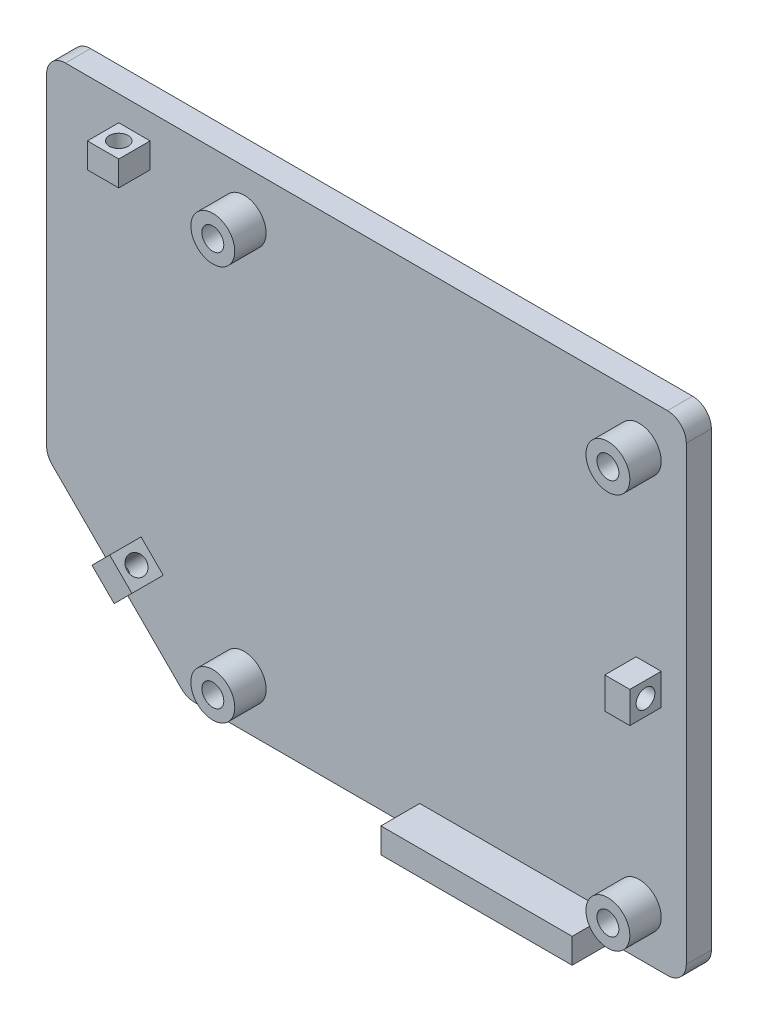
from build123d import *

# Parameters (mm, degrees)
CROQUIS1_W                 = 102
CROQUIS1_H                 = 78
SALIENTE_EXTRUIR1_DEPTH    = 4
CROQUIS2_R                 = 1.75
CORTAR_EXTRUIR1_DEPTH      = 4
CROQUIS3_R                 = 3.5
CROQUIS3_R_2               = 1.75
SALIENTE_EXTRUIR2_DEPTH    = 5
CROQUIS4_W                 = 30.5
CROQUIS4_H                 = 4
SALIENTE_EXTRUIR3_DEPTH    = 6.2
SALIENTE_EXTRUIR4_DEPTH    = 5
CROQUIS7_R                 = 1.5
CORTAR_EXTRUIR3_DEPTH      = 5
CORTAR_EXTRUIR5_DEPTH      = 7.2
CORTAR_EXTRUIR5_DEPTH_BACK = 5
CROQUIS11_R                = 1.5
CORTAR_EXTRUIR6_DEPTH      = 4
SALIENTE_EXTRUIR5_DEPTH    = 5
CROQUIS13_R                = 1.5
CORTAR_EXTRUIR7_DEPTH      = 5
REDONDEO1_R                = 3


with BuildPart() as part:
    # Croquis1 → Saliente-Extruir1 (new body)
    with BuildSketch(Plane.XY):
        with Locations((51, 39)):
            Rectangle(CROQUIS1_W, CROQUIS1_H)
    extrude(amount=SALIENTE_EXTRUIR1_DEPTH)

    # Croquis2 → Cortar-Extruir1 (cut)
    with BuildSketch(Plane.XY.offset(4)):
        with Locations((94.5, 70.5)):
            Circle(CROQUIS2_R)
        with Locations((31.5, 70.5)):
            Circle(CROQUIS2_R)
        with Locations((31.5, 7.5)):
            Circle(CROQUIS2_R)
        with Locations((94.5, 7.5)):
            Circle(CROQUIS2_R)
    extrude(amount=-CORTAR_EXTRUIR1_DEPTH, mode=Mode.SUBTRACT)

    # Croquis3 → Saliente-Extruir2 (add)
    with BuildSketch(Plane.XY.offset(4)):
        with Locations((31.5, 70.5)):
            Circle(CROQUIS3_R)
        with Locations((31.5, 70.5)):
            Circle(CROQUIS3_R_2, mode=Mode.SUBTRACT)
        with Locations((94.5, 70.5)):
            Circle(CROQUIS3_R)
        with Locations((94.5, 70.5)):
            Circle(CROQUIS3_R_2, mode=Mode.SUBTRACT)
        with Locations((31.5, 7.5)):
            Circle(CROQUIS3_R)
        with Locations((31.5, 7.5)):
            Circle(CROQUIS3_R_2, mode=Mode.SUBTRACT)
        with Locations((94.5, 7.5)):
            Circle(CROQUIS3_R)
        with Locations((94.5, 7.5)):
            Circle(CROQUIS3_R_2, mode=Mode.SUBTRACT)
    extrude(amount=SALIENTE_EXTRUIR2_DEPTH)

    # Croquis4 → Saliente-Extruir3 (add)
    with BuildSketch(Plane.XY.offset(4)):
        with Locations((74.75, 2)):
            Rectangle(CROQUIS4_W, CROQUIS4_H)
    extrude(amount=SALIENTE_EXTRUIR3_DEPTH)

    # Croquis5 → Saliente-Extruir4 (add)
    with BuildSketch(Plane.XY.offset(4)):
        Polygon((14, 70), (11.5, 70), (11.5, 74), (14, 74), (16.5, 74), (16.5, 70), align=None)
        Polygon((98, 39), (98, 41.5), (94, 41.5), (94, 39), (94, 36.5), (98, 36.5), align=None)
    extrude(amount=SALIENTE_EXTRUIR4_DEPTH)

    # Croquis7 → Cortar-Extruir3 (cut)
    with BuildSketch(Plane(origin=(98, 0, 0), x_dir=(0, 0, -1), z_dir=(1, 0, 0))):
        with Locations((-6.5, 39)):
            Circle(CROQUIS7_R)
    extrude(amount=-CORTAR_EXTRUIR3_DEPTH, mode=Mode.SUBTRACT)

    # Croquis8 → Cortar-Extruir5 (cut, two sides)
    with BuildSketch(Plane.XY.offset(4)) as cortar_extruir5_sk:
        Polygon((0, 0), (22.34, 0), (0, 22.34), align=None)
    extrude(amount=CORTAR_EXTRUIR5_DEPTH, mode=Mode.SUBTRACT)
    extrude(cortar_extruir5_sk.sketch, amount=-CORTAR_EXTRUIR5_DEPTH_BACK, mode=Mode.SUBTRACT)

    # Croquis11 → Cortar-Extruir6 (cut)
    with BuildSketch(Plane(origin=(0, 74, 0), x_dir=(1, 0, 0), z_dir=(0, 1, 0))):
        with Locations((14, -6.5)):
            Circle(CROQUIS11_R)
    extrude(amount=-CORTAR_EXTRUIR6_DEPTH, mode=Mode.SUBTRACT)

    # Croquis12 → Saliente-Extruir5 (add)
    with BuildSketch(Plane.XY.offset(4)):
        Polygon((13.998427125, 13.998427125), (15.766194078, 12.230660172), (18.594621202, 15.059087297), (15.059087297, 18.594621202), (12.230660172, 15.766194078), align=None)
    extrude(amount=SALIENTE_EXTRUIR5_DEPTH)

    # Croquis13 → Cortar-Extruir7 (cut)
    with BuildSketch(Plane(origin=(13.998427125, 13.998427125, 0), x_dir=(0, 0, 1), z_dir=(-0.707106781, -0.707106781, 0))):
        with Locations((6.5, 0)):
            Circle(CROQUIS13_R)
    extrude(amount=-CORTAR_EXTRUIR7_DEPTH, mode=Mode.SUBTRACT)

    # Redondeo1
    redondeo1_edges = [part.edges().sort_by_distance(p)[0] for p in [
        (0, 22.34, 2),
        (22.34, 0, 2),
        (0, 78, 2),
        (102, 78, 2),
        (102, 0, 2),
    ]]
    fillet(redondeo1_edges, radius=REDONDEO1_R)


solid = part.part
